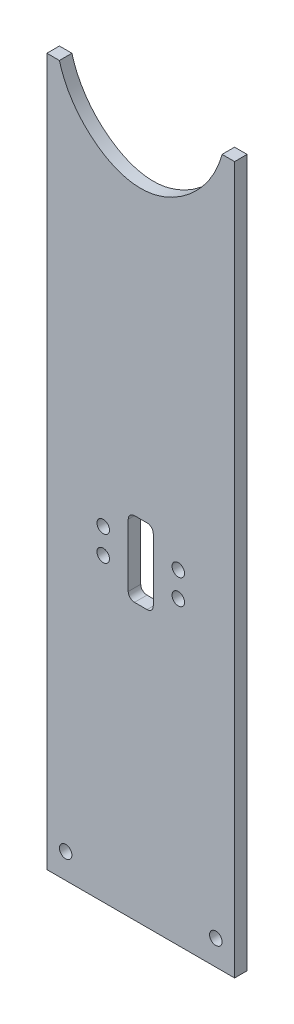
from build123d import *

# Parameters (mm, degrees)
SKETCH1_W           = 95.25
SKETCH1_H           = 406.4
BOSS_EXTRUDE1_DEPTH = 6.35
CUT_EXTRUDE1_DEPTH  = 6.35
SKETCH3_R           = 3.175
CUT_EXTRUDE2_DEPTH  = 6.35
SKETCH4_R           = 3.175
CUT_EXTRUDE3_DEPTH  = 7.3500001


with BuildPart() as part:
    # Sketch1 → Boss-Extrude1 (new body)
    with BuildSketch(Plane.XY):
        with Locations((47.625, 203.2)):
            Rectangle(SKETCH1_W, SKETCH1_H)
    extrude(amount=BOSS_EXTRUDE1_DEPTH)

    # Sketch2 → Cut-Extrude1 (cut)
    with BuildSketch(Plane(origin=(0, 0, 0), x_dir=(-1, 0, 0), z_dir=(0, 0, -1))):
        with BuildLine():
            Line((-95.25, 358.795116355), (-88.899916478, 358.795116355))
            add(Edge.make_bspline(
                [(-88.899916478, 358.795116355), (-88.746918957, 358.220859299), (-87.981388016, 355.548098122), (-86.156732479, 350.776147046), (-82.793447186, 344.659309891), (-78.553663698, 339.00035146), (-73.568328984, 333.940394202), (-67.902765315, 329.602048826), (-61.759947665, 326.175234429), (-56.011278232, 324.163968737), (-51.274161129, 323.327012567), (-47.6263932, 323.106329306), (-43.964779676, 323.327682292), (-39.230133038, 324.167914788), (-33.493030626, 326.166537812), (-27.199275842, 329.696450217), (-19.753743135, 335.438425446), (-13.509536081, 342.720425859), (-9.091517456, 350.781784077), (-7.361400097, 355.320896006), (-6.582808256, 357.943053332), (-6.425755246, 358.510985771), (-6.349961226, 358.795396351)],
                knots=[0.244653944, 0.244653944, 0.244653944, 0.244653944, 0.252466444, 0.28125, 0.3125, 0.34375, 0.375, 0.40625, 0.4375, 0.46875, 0.484375, 0.5, 0.515625, 0.53125, 0.5625, 0.59375, 0.625, 0.6875, 0.71875, 0.747082052, 0.750988302, 0.754894552, 0.754894552, 0.754894552, 0.754894552], degree=3))
            Line((-6.349961226, 358.795396351), (0, 358.795396351))
            Line((0, 358.795396351), (0, 406.4))
            Line((0, 406.4), (-95.25, 406.4))
            Line((-95.25, 406.4), (-95.25, 358.795116355))
        make_face()
    extrude(amount=-CUT_EXTRUDE1_DEPTH, mode=Mode.SUBTRACT)

    # Sketch3 → Cut-Extrude2 (cut)
    with BuildSketch(Plane(origin=(0, 0, 0), x_dir=(-1, 0, 0), z_dir=(0, 0, -1))):
        with Locations((-28.575, 165.1)):
            Circle(SKETCH3_R)
        with Locations((-66.675, 165.1)):
            Circle(SKETCH3_R)
        with Locations((-66.675, 152.4)):
            Circle(SKETCH3_R)
        with Locations((-28.575, 152.4)):
            Circle(SKETCH3_R)
        with BuildLine():
            Line((-50.8, 177.8), (-44.45, 177.8))
            ThreePointArc((-44.45, 177.8), (-42.20493597, 176.87006403), (-41.275, 174.625))
            Line((-41.275, 174.625), (-41.275, 142.875))
            ThreePointArc((-41.275, 142.875), (-42.20493597, 140.62993597), (-44.45, 139.7))
            Line((-44.45, 139.7), (-50.8, 139.7))
            ThreePointArc((-50.8, 139.7), (-53.04506403, 140.62993597), (-53.975, 142.875))
            Line((-53.975, 142.875), (-53.975, 174.625))
            ThreePointArc((-53.975, 174.625), (-53.04506403, 176.87006403), (-50.8, 177.8))
        make_face()
    extrude(amount=-CUT_EXTRUDE2_DEPTH, mode=Mode.SUBTRACT)

    # Sketch4 → Cut-Extrude3 (cut, through all)
    with BuildSketch(Plane(origin=(0, 0, 0), x_dir=(-1, 0, 0), z_dir=(0, 0, -1))):
        with Locations((-9.525, 12.7)):
            Circle(SKETCH4_R)
        with Locations((-85.725, 12.7)):
            Circle(SKETCH4_R)
    extrude(amount=-CUT_EXTRUDE3_DEPTH, mode=Mode.SUBTRACT)


solid = part.part
